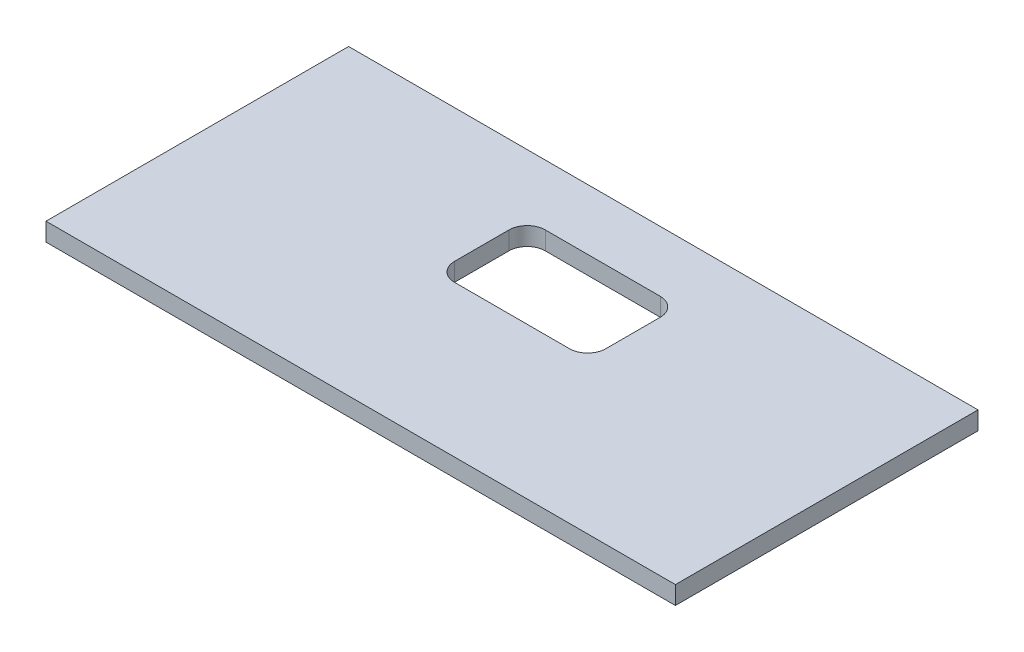
from build123d import *

# Parameters (mm, degrees)
IZIM1_W                     = 104
IZIM1_H                     = 50
Y_KSEKLIK_EKSTR_ZYON1_DEPTH = 3


with BuildPart() as part:
    # Çizim1 → Yükseklik-Ekstrüzyon1 (new body)
    with BuildSketch(Plane(origin=(0, 0, 0), x_dir=(1, 0, 0), z_dir=(0, 1, 0))):
        with Locations((52, -25)):
            Rectangle(IZIM1_W, IZIM1_H)
        with BuildLine():
            Line((42.5, -10), (61.5, -10))
            ThreePointArc((61.5, -10), (63.621320344, -10.878679656), (64.5, -13))
            Line((64.5, -13), (64.5, -22))
            ThreePointArc((64.5, -22), (63.621320344, -24.121320344), (61.5, -25))
            Line((61.5, -25), (42.5, -25))
            ThreePointArc((42.5, -25), (40.378679656, -24.121320344), (39.5, -22))
            Line((39.5, -22), (39.5, -13))
            ThreePointArc((39.5, -13), (40.378679656, -10.878679656), (42.5, -10))
        make_face(mode=Mode.SUBTRACT)
    extrude(amount=Y_KSEKLIK_EKSTR_ZYON1_DEPTH)


solid = part.part
